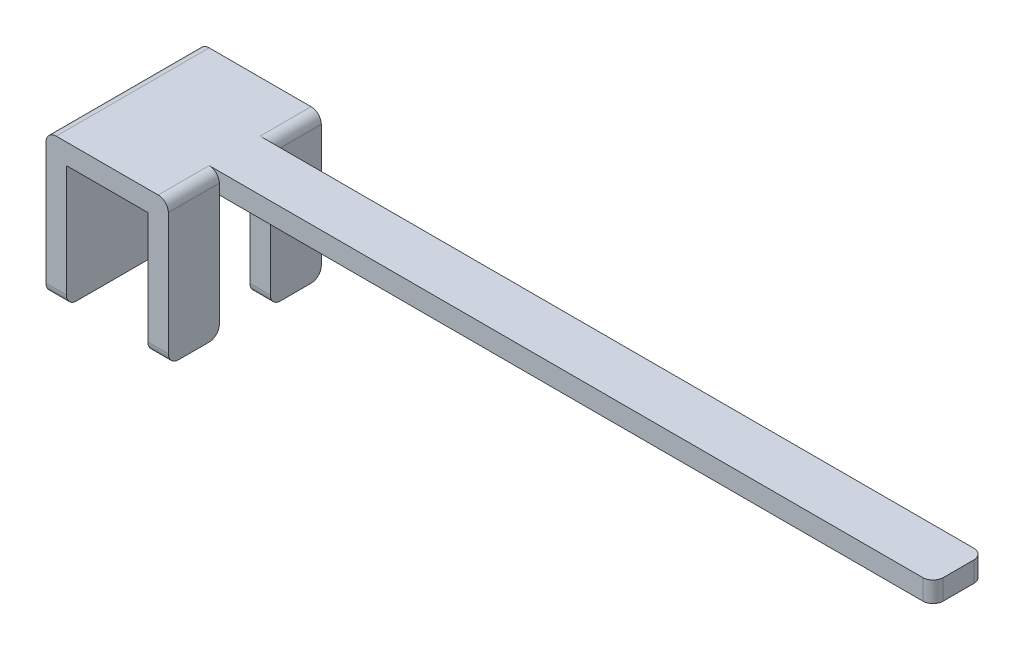
from build123d import *

# Parameters (mm, degrees)
BOSS_EXTRUDE1_DEPTH = 1.5
BOSS_EXTRUDE3_START = -1
SKETCH5_W           = 7.6
SKETCH5_H           = 0.2
BOSS_EXTRUDE3_DEPTH = 0.5
SKETCH6_W           = 0.5
SKETCH6_H           = 1.2
CUT_EXTRUDE2_DEPTH  = 0.5
FILLET2_R           = 0.1


with BuildPart() as part:
    # Sketch1 → Boss-Extrude1 (new body)
    with BuildSketch(Plane.XY):
        with BuildLine():
            Line((-0.6, 0.7), (-0.6, -0.6))
            Line((-0.6, -0.6), (-0.4, -0.6))
            Line((-0.4, -0.6), (-0.4, 0.6))
            Line((-0.4, 0.6), (0.4, 0.6))
            Line((0.4, 0.6), (0.4, -0.6))
            Line((0.4, -0.6), (0.6, -0.6))
            Line((0.6, -0.6), (0.6, 0.7))
            ThreePointArc((0.6, 0.7), (0.570710678, 0.770710678), (0.5, 0.8))
            Line((0.5, 0.8), (-0.5, 0.8))
            ThreePointArc((-0.5, 0.8), (-0.570710678, 0.770710678), (-0.6, 0.7))
        make_face()
    extrude(amount=BOSS_EXTRUDE1_DEPTH)

    # Sketch5 → Boss-Extrude3 (add)
    with BuildSketch(Plane.XY.offset(1.5).offset(BOSS_EXTRUDE3_START)):
        with Locations((3.8, 0.7)):
            Rectangle(SKETCH5_W, SKETCH5_H)
    extrude(amount=BOSS_EXTRUDE3_DEPTH)

    # Sketch6 → Cut-Extrude2 (cut)
    with BuildSketch(Plane(origin=(0.6, 0, 0), x_dir=(0, 0, -1), z_dir=(1, 0, 0))):
        with Locations((-0.75, 0)):
            Rectangle(SKETCH6_W, SKETCH6_H)
    extrude(amount=-CUT_EXTRUDE2_DEPTH, mode=Mode.SUBTRACT)

    # Fillet2
    fillet2_edges = [part.edges().sort_by_distance(p)[0] for p in [
        (-0.5, -0.6, 0),
        (0.5, -0.6, 0),
        (-0.5, -0.6, 1.5),
        (7.6, 0.7, 1),
        (7.6, 0.7, 0.5),
        (0.5, -0.6, 0.5),
        (0.5, -0.6, 1),
        (0.5, -0.6, 1.5),
    ]]
    fillet(fillet2_edges, radius=FILLET2_R)


solid = part.part
